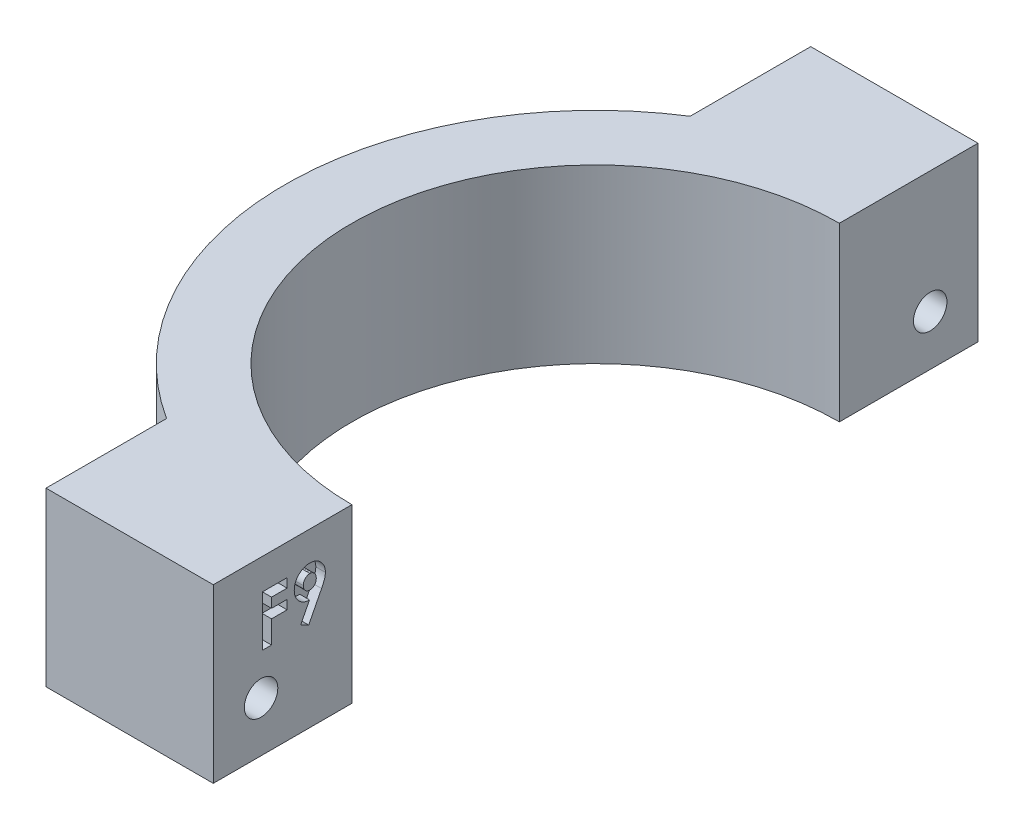
from build123d import *

# Parameters (mm, degrees)
BOSS_EXTRUDE1_DEPTH = 18
SKETCH2_R           = 1.75
CUT_EXTRUDE1_DEPTH  = 33.5
CUT_EXTRUDE2_DEPTH  = 1
CUT_EXTRUDE3_DEPTH  = 5


with BuildPart() as part:
    # Sketch1 → Boss-Extrude1 (new body)
    with BuildSketch(Plane(origin=(0, 0, 0), x_dir=(1, 0, 0), z_dir=(0, 1, 0))):
        with BuildLine():
            Line((-11.998275301, 32.528571429), (-29.498275301, 32.528571429))
            Line((-29.498275301, 32.528571429), (-29.498275301, 19.914699304))
            ThreePointArc((-29.498275301, 19.914699304), (-21.114218589, 23.723916882), (-11.998275301, 25.028571429))
            Line((-11.998275301, 25.028571429), (-11.998275301, 32.528571429))
        make_face()
        with BuildLine():
            ThreePointArc((-11.998275301, 25.028571429), (-21.114218589, 23.723916882), (-29.498275301, 19.914699304))
            ThreePointArc((-29.498275301, 19.914699304), (-44.498275301, -7.471428571), (-29.498275301, -34.857556447))
            ThreePointArc((-29.498275301, -34.857556447), (-21.114218589, -38.666774025), (-11.998275301, -39.971428571))
            Line((-11.998275301, -39.971428571), (-11.998275301, -32.971428571))
            ThreePointArc((-11.998275301, -32.971428571), (-37.498275301, -7.471428571), (-11.998275301, 18.028571429))
            Line((-11.998275301, 18.028571429), (-11.998275301, 25.028571429))
        make_face()
        with BuildLine():
            Line((-29.498275301, -34.857556447), (-29.498275301, -47.471428571))
            Line((-29.498275301, -47.471428571), (-11.998275301, -47.471428571))
            Line((-11.998275301, -47.471428571), (-11.998275301, -39.971428571))
            ThreePointArc((-11.998275301, -39.971428571), (-21.114218589, -38.666774025), (-29.498275301, -34.857556447))
        make_face()
    extrude(amount=BOSS_EXTRUDE1_DEPTH)

    # Sketch2 → Cut-Extrude1 (cut, through all)
    with BuildSketch(Plane(origin=(-11.998275301, 0, 0), x_dir=(0, 0, -1), z_dir=(1, 0, 0))):
        with Locations((-42.471428571, 5.25)):
            Circle(SKETCH2_R)
        with Locations((27.528571429, 5.25)):
            Circle(SKETCH2_R)
    extrude(amount=-CUT_EXTRUDE1_DEPTH, mode=Mode.SUBTRACT)

    # Sketch3 → Cut-Extrude2 (cut)
    with BuildSketch(Plane(origin=(-11.998275301, 0, 0), x_dir=(0, 0, -1), z_dir=(1, 0, 0))):
        Polygon((-42.326802517, 14.778828324), (-39.748811064, 14.778828324), (-39.748811064, 13.829042), (-41.377016192, 13.829042), (-41.377016192, 12.811413795), (-39.748811064, 12.811413795), (-39.748811064, 11.86162747), (-41.377016192, 11.86162747), (-41.377016192, 9.487161658), (-42.326802517, 9.487161658), align=None)
        with BuildLine():
            Line((-37.488828425, 9.351477897), (-38.330491753, 9.775489649))
            Line((-38.330491753, 9.775489649), (-37.408266192, 11.590259948))
            add(Edge.make_bspline(
                [(-37.408266192, 11.590259948), (-37.462753396, 11.591648755), (-37.569724958, 11.594375318), (-37.727232239, 11.617033031), (-37.87785266, 11.655711194), (-38.023361539, 11.707201572), (-38.161746535, 11.77622976), (-38.294685676, 11.858611279), (-38.420338635, 11.95759149), (-38.539294546, 12.068849341), (-38.647905095, 12.191825278), (-38.742176754, 12.324083818), (-38.824345348, 12.462269948), (-38.888244154, 12.60950332), (-38.939568, 12.76303987), (-38.977067789, 12.92367432), (-38.998111679, 13.092111431), (-39.00105302, 13.206747887), (-39.00255038, 13.265106369)],
                knots=[0, 0, 0, 0, 0.000163413, 0.000320819, 0.000476106, 0.000629341, 0.000782939, 0.000939124, 0.001097732, 0.001261968, 0.001427204, 0.001589, 0.001748625, 0.001908563, 0.002069464, 0.002233772, 0.002402593, 0.002577655, 0.002577655, 0.002577655, 0.002577655], degree=3))
            add(Edge.make_bspline(
                [(-39.00255038, 13.265106369), (-39.001161497, 13.321713522), (-38.99842473, 13.433256746), (-38.975695616, 13.5969659), (-38.938289378, 13.754150604), (-38.88696936, 13.904784157), (-38.818649356, 14.047850808), (-38.738682529, 14.185590652), (-38.640926713, 14.315153998), (-38.530495897, 14.437101726), (-38.409635229, 14.548662366), (-38.281412206, 14.646751431), (-38.146409838, 14.728744465), (-38.006363041, 14.797603487), (-37.858740367, 14.849050664), (-37.705675127, 14.887867179), (-37.546027089, 14.910269855), (-37.43766133, 14.913086693), (-37.382825487, 14.914512085)],
                knots=[0, 0, 0, 0, 0.000169767, 0.000334522, 0.000494702, 0.000653936, 0.000810896, 0.000969607, 0.001130944, 0.0012968, 0.001462589, 0.001623717, 0.001780246, 0.001935749, 0.002090981, 0.002248323, 0.002408879, 0.002573351, 0.002573351, 0.002573351, 0.002573351], degree=3))
            add(Edge.make_bspline(
                [(-37.382825487, 14.914512085), (-37.32548798, 14.913331855), (-37.212741531, 14.911011091), (-37.047695871, 14.885402378), (-36.889786863, 14.846113929), (-36.738372898, 14.792752199), (-36.595333717, 14.720329287), (-36.459472442, 14.633529923), (-36.331240989, 14.530433614), (-36.212016472, 14.414011914), (-36.103583105, 14.287381533), (-36.007470418, 14.154830073), (-35.92673168, 14.016616709), (-35.860601716, 13.873974949), (-35.809086806, 13.726681326), (-35.773676871, 13.574526911), (-35.750168601, 13.417771894), (-35.747493829, 13.311480409), (-35.746140124, 13.257686164)],
                knots=[0, 0, 0, 0, 0.000171885, 0.000337989, 0.000499701, 0.000659639, 0.000818449, 0.000979588, 0.001142488, 0.001311152, 0.001478788, 0.001642063, 0.001801688, 0.0019582, 0.00211308, 0.00226889, 0.002426296, 0.002587592, 0.002587592, 0.002587592, 0.002587592], degree=3))
            add(Edge.make_bspline(
                [(-35.746140124, 13.257686164), (-35.746878854, 13.21665857), (-35.748366821, 13.134019773), (-35.762997646, 13.010093938), (-35.785195556, 12.885824631), (-35.810960929, 12.781344964), (-35.837972338, 12.693274952), (-35.864257515, 12.618563879), (-35.897982171, 12.535620561), (-35.935639121, 12.443889047), (-35.9792503, 12.343771591), (-36.029719907, 12.235746792), (-36.083997697, 12.118212537), (-36.124005786, 12.037844215), (-36.144711171, 11.996251201)],
                knots=[0, 0, 0, 0, 0.000123036, 0.000247823, 0.000373829, 0.000501605, 0.000570344, 0.000650135, 0.000739108, 0.000838914, 0.000947623, 0.001066672, 0.001196607, 0.001335984, 0.001335984, 0.001335984, 0.001335984], degree=3))
            Line((-36.144711171, 11.996251201), (-37.488828425, 9.351477897))
        make_face()
        with BuildLine():
            add(Edge.make_bspline(
                [(-37.3616249, 12.472204393), (-37.316115096, 12.474883687), (-37.227199244, 12.480118421), (-37.099477536, 12.520594498), (-36.985173101, 12.58986006), (-36.883860931, 12.68188028), (-36.800139654, 12.794149159), (-36.739268808, 12.921957298), (-36.70177424, 13.062657931), (-36.697913156, 13.160632443), (-36.695926449, 13.211044871)],
                knots=[0, 0, 0, 0, 0.000136382, 0.000266459, 0.00039717, 0.000534504, 0.00067464, 0.000814508, 0.000956947, 0.001107922, 0.001107922, 0.001107922, 0.001107922], degree=3))
            add(Edge.make_bspline(
                [(-36.695926449, 13.211044871), (-36.698319221, 13.262505994), (-36.702973734, 13.362610164), (-36.740827484, 13.506688151), (-36.805511929, 13.636926106), (-36.893511418, 13.750138756), (-36.996249672, 13.84488328), (-37.111136974, 13.914091604), (-37.23538362, 13.956887813), (-37.321366646, 13.962095071), (-37.364804988, 13.96472576)],
                knots=[0, 0, 0, 0, 0.00015423, 0.000300014, 0.00044318, 0.000587566, 0.000727895, 0.000860059, 0.000987439, 0.001117495, 0.001117495, 0.001117495, 0.001117495], degree=3))
            add(Edge.make_bspline(
                [(-37.364804988, 13.96472576), (-37.410716877, 13.962161178), (-37.500864495, 13.95712564), (-37.630172561, 13.914432203), (-37.749374298, 13.84655291), (-37.853470467, 13.751486921), (-37.943561709, 13.639765246), (-38.006384791, 13.50908768), (-38.046128852, 13.366015125), (-38.050512553, 13.265731436), (-38.052764056, 13.214224959)],
                knots=[0, 0, 0, 0, 0.000137436, 0.000269855, 0.000404228, 0.000546134, 0.000690333, 0.00083208, 0.000978137, 0.001132367, 0.001132367, 0.001132367, 0.001132367], degree=3))
            add(Edge.make_bspline(
                [(-38.052764056, 13.214224959), (-38.050412222, 13.163452669), (-38.04583815, 13.064705867), (-38.007502778, 12.923207265), (-37.945058299, 12.794722755), (-37.859692241, 12.681568477), (-37.75454228, 12.589094862), (-37.635152594, 12.520567119), (-37.501976162, 12.48000867), (-37.409250814, 12.474852647), (-37.3616249, 12.472204393)],
                knots=[0, 0, 0, 0, 0.000152117, 0.000295852, 0.00043618, 0.000578438, 0.000718145, 0.000853439, 0.000988579, 0.00113129, 0.00113129, 0.00113129, 0.00113129], degree=3))
        make_face(mode=Mode.SUBTRACT)
    extrude(amount=-CUT_EXTRUDE2_DEPTH, mode=Mode.SUBTRACT)

    # Sketch4 → Cut-Extrude3 (cut)
    with BuildSketch(Plane.ZY.offset(29.498275301)):
        Polygon((-25.391799088, 2.901056132), (-24.425940196, 5.926027195), (-26.562712537, 8.274971063), (-29.665343769, 7.598943868), (-30.631202661, 4.573972805), (-28.49443032, 2.225028937), align=None)
        Polygon((44.716794169, 3.004634402), (45.538655018, 6.071860849), (43.293289421, 8.317226447), (40.226062974, 7.495365598), (39.404202124, 4.428139151), (41.649567722, 2.182773553), align=None)
    extrude(amount=-CUT_EXTRUDE3_DEPTH, mode=Mode.SUBTRACT)


solid = part.part
